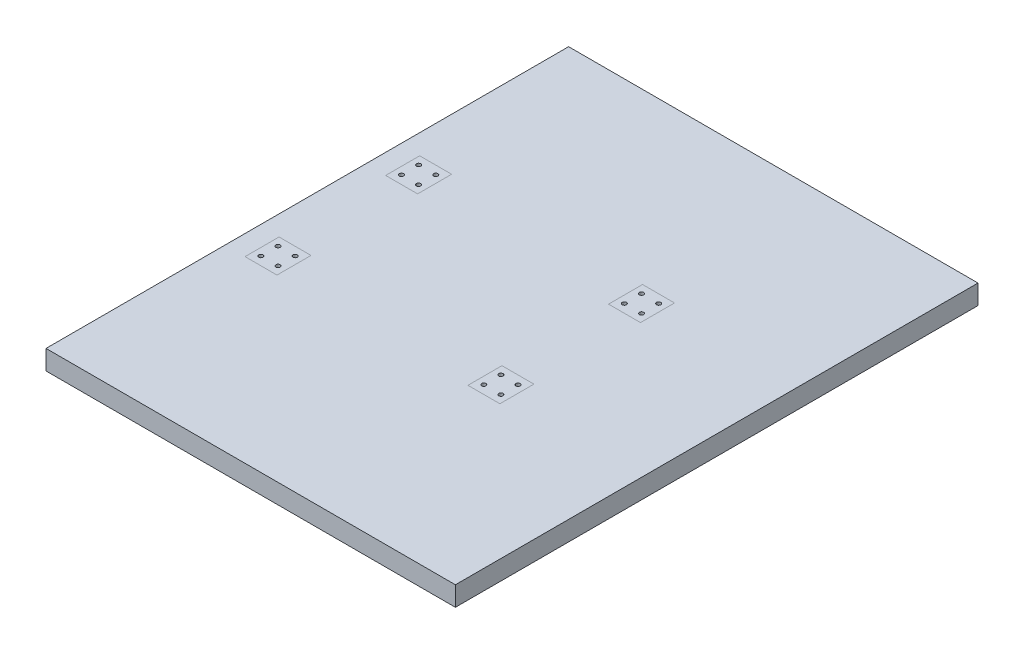
from build123d import *

# Parameters (mm, degrees)
SKETCH1_W               = 1028.7
SKETCH1_H               = 50.8
BOSS_EXTRUDE1_DEPTH     = 704.85
SKETCH2_W               = 508
SKETCH2_H               = 100
SKETCH2_H_2             = 403.25
CUT_EXTRUDE1_DEPTH      = 585.2
CUT_EXTRUDE1_DEPTH_BACK = 585.2
SKETCH3_W               = 1193.8
SKETCH3_H               = 762
BOSS_EXTRUDE2_DEPTH     = 28.5
SKETCH4_R               = 3.1
CUT_EXTRUDE2_DEPTH      = 28.5
SKETCH5_R               = 1000
SKETCH5_W               = 596.9
SKETCH5_H               = 28.5
CUT_EXTRUDE3_DEPTH      = 369.3
CUT_EXTRUDE3_DEPTH_BACK = 394.7


with BuildPart() as part:
    # Sketch1 → Boss-Extrude1 (new body)
    with BuildSketch(Plane(origin=(0, 0, 0), x_dir=(1, 0, 0), z_dir=(0, 1, 0))):
        Polygon((-584.2, 355.6), (-584.2, 254), (-552.45, 254), (-514.35, 254), (-482.6, 254), (-482.6, 355.6), align=None)
        Polygon((584.2, 355.6), (482.6, 355.6), (482.6, 254), (514.35, 254), (552.45, 254), (584.2, 254), align=None)
        Polygon((482.6, -254), (482.6, -355.6), (584.2, -355.6), (584.2, -254), (552.45, -254), (514.35, -254), align=None)
        Polygon((-552.45, -254), (-584.2, -254), (-584.2, -355.6), (-482.6, -355.6), (-482.6, -254), (-514.35, -254), align=None)
        Polygon((-514.35, 254), (-552.45, 254), (-552.45, -254), (-514.35, -254), (-514.35, -25.4), (-514.35, 25.4), align=None)
        Rectangle(SKETCH1_W, SKETCH1_H)
        Polygon((514.35, 254), (514.35, 25.4), (514.35, -25.4), (514.35, -254), (552.45, -254), (552.45, 254), align=None)
    extrude(amount=-BOSS_EXTRUDE1_DEPTH)

    # Sketch2 → Cut-Extrude1 (cut, two sides)
    with BuildSketch(Plane(origin=(0, 0, 0), x_dir=(0, 0, -1), z_dir=(1, 0, 0))) as cut_extrude1_sk:
        with Locations((0, -50)):
            Rectangle(SKETCH2_W, SKETCH2_H)
        with Locations((0, -352.425)):
            Rectangle(SKETCH2_W, SKETCH2_H_2)
        with Locations((0, -654.85)):
            Rectangle(SKETCH2_W, SKETCH2_H)
    extrude(amount=CUT_EXTRUDE1_DEPTH, mode=Mode.SUBTRACT)
    extrude(cut_extrude1_sk.sketch, amount=-CUT_EXTRUDE1_DEPTH_BACK, mode=Mode.SUBTRACT)


with BuildPart() as body_2:
    # Sketch3 → Boss-Extrude2 (new body)
    with BuildSketch(Plane(origin=(0, 0, 0), x_dir=(1, 0, 0), z_dir=(0, 1, 0))):
        with Locations((0, 12.7)):
            Rectangle(SKETCH3_W, SKETCH3_H)
    extrude(amount=BOSS_EXTRUDE2_DEPTH)

    # Sketch4 → Cut-Extrude2 (cut)
    with BuildSketch(Plane(origin=(0, 28.5, 0), x_dir=(1, 0, 0), z_dir=(0, 1, 0))):
        with Locations((-556.9, 110)):
            Circle(SKETCH4_R)
        with Locations((-531.9, 110)):
            Circle(SKETCH4_R)
        with Locations((-531.9, 135)):
            Circle(SKETCH4_R)
        with Locations((-556.9, 135)):
            Circle(SKETCH4_R)
        with Locations((-231.9, 135)):
            Circle(SKETCH4_R)
        with Locations((-206.9, 135)):
            Circle(SKETCH4_R)
        with Locations((-231.9, 110)):
            Circle(SKETCH4_R)
        with Locations((-206.9, 110)):
            Circle(SKETCH4_R)
        with Locations((-206.9, -70)):
            Circle(SKETCH4_R)
        with Locations((-231.9, -70)):
            Circle(SKETCH4_R)
        with Locations((-231.9, -95)):
            Circle(SKETCH4_R)
        with Locations((-206.9, -95)):
            Circle(SKETCH4_R)
        with Locations((-531.9, -70)):
            Circle(SKETCH4_R)
        with Locations((-531.9, -95)):
            Circle(SKETCH4_R)
        with Locations((-556.9, -70)):
            Circle(SKETCH4_R)
        with Locations((-556.9, -95)):
            Circle(SKETCH4_R)
    cut_extrude2 = extrude(amount=-CUT_EXTRUDE2_DEPTH, mode=Mode.SUBTRACT)

    # Mirror1: Cut-Extrude2 across plane
    add(cut_extrude2.mirror(Plane(origin=(0, 0, 0), x_dir=(0, 0, 1), z_dir=(1, 0, 0))), mode=Mode.SUBTRACT)


with BuildPart() as cut_extrude3_tool:
    # Sketch5 → Cut-Extrude3 (new body, two sides)
    with BuildSketch(Plane.XY) as cut_extrude3_sk:
        Circle(SKETCH5_R)
        with Locations((-298.45, 14.25)):
            Rectangle(SKETCH5_W, SKETCH5_H, mode=Mode.SUBTRACT)
    extrude(amount=CUT_EXTRUDE3_DEPTH)
    extrude(cut_extrude3_sk.sketch, amount=-CUT_EXTRUDE3_DEPTH_BACK)


with BuildPart() as part_1:
    add(part.part)

    # Cut-Extrude3: cut by cut_extrude3_tool
    add(cut_extrude3_tool.part, mode=Mode.SUBTRACT)


with BuildPart() as body_2_1:
    add(body_2.part)

    # Cut-Extrude3: cut by cut_extrude3_tool
    add(cut_extrude3_tool.part, mode=Mode.SUBTRACT)


solid = body_2_1.part
